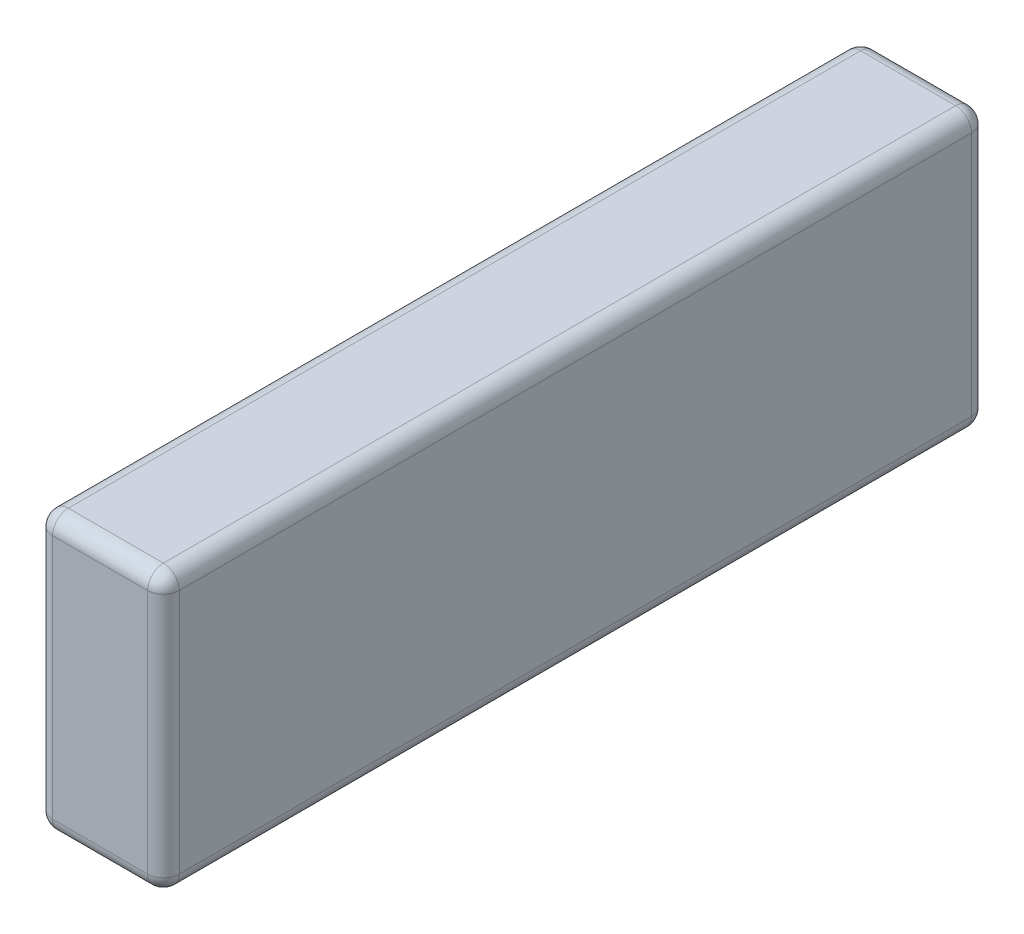
from build123d import *

# Parameters (mm, degrees)
SKETCH1_W           = 16
SKETCH1_H           = 104
BOSS_EXTRUDE1_DEPTH = 35
FILLET1_R           = 2


with BuildPart() as part:
    # Sketch1 → Boss-Extrude1 (new body)
    with BuildSketch(Plane(origin=(0, 0, 0), x_dir=(1, 0, 0), z_dir=(0, 1, 0))):
        Rectangle(SKETCH1_W, SKETCH1_H)
    extrude(amount=BOSS_EXTRUDE1_DEPTH)

    # Fillet1
    fillet1_edges = [part.edges().sort_by_distance(p)[0] for p in [
        (-8, 35, 0),
        (0, 35, 52),
        (8, 35, 0),
        (0, 0, 52),
        (-8, 0, 0),
        (0, 0, -52),
        (8, 0, 0),
        (8, 17.5, 52),
        (-8, 17.5, 52),
        (-8, 17.5, -52),
        (8, 17.5, -52),
        (0, 35, -52),
    ]]
    fillet(fillet1_edges, radius=FILLET1_R)


solid = part.part
